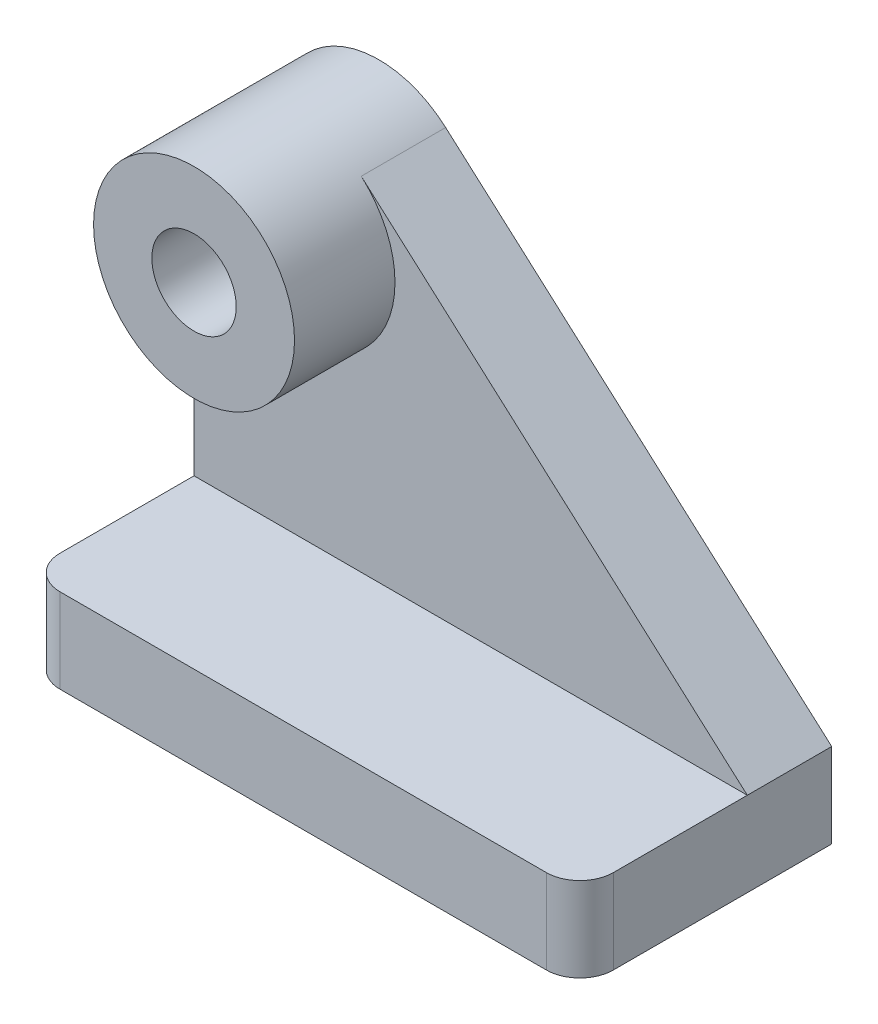
from build123d import *

# Parameters (mm, degrees)
SKETCH1_W               = 104.902
SKETCH1_H               = 47.752
EXTRUDE1_DEPTH          = 16.002
FILLET1_R               = 6.35
SKETCH2_W               = 104.902
SKETCH2_H               = 16.002
EXTRUDE2_DEPTH          = 69.85
CUT_EXTRUDE1_DEPTH      = 69.85
CUT_EXTRUDE3_DEPTH      = 32.75
CUT_EXTRUDE3_DEPTH_BACK = 17.002
SKETCH5_R               = 19.05
EXTRUDE3_DEPTH          = 19.05
SKETCH6_R               = 8.001
CUT_EXTRUDE4_DEPTH      = 36.052


with BuildPart() as part:
    # Sketch1 → Extrude1 (new body)
    with BuildSketch(Plane(origin=(0, 0, 0), x_dir=(1, 0, 0), z_dir=(0, 1, 0))):
        with Locations((-26.583821429, -19.496767857)):
            Rectangle(SKETCH1_W, SKETCH1_H)
    extrude(amount=EXTRUDE1_DEPTH)

    # Fillet1
    fillet1_edges = [part.edges().sort_by_distance(p)[0] for p in [
        (25.867178571, 8.001, 43.372767857),
        (-79.034821429, 8.001, 43.372767857),
    ]]
    fillet(fillet1_edges, radius=FILLET1_R)

    # Sketch2 → Extrude2 (add)
    with BuildSketch(Plane(origin=(0, 16.002, 0), x_dir=(-1, 0, 0), z_dir=(0, 1, 0))):
        with Locations((26.583821429, 3.621767857)):
            Rectangle(SKETCH2_W, SKETCH2_H)
    extrude(amount=EXTRUDE2_DEPTH)

    # Sketch3 → Cut-Extrude1 (cut)
    with BuildSketch(Plane.XY.offset(11.622767857)):
        with BuildLine():
            ThreePointArc((-59.984821429, 85.852), (-53.216510402, 84.609090325), (-47.331390899, 81.042547596))
            Line((-47.331390899, 81.042547596), (25.867178571, 16.002))
            Line((25.867178571, 16.002), (25.867178571, 85.852))
            Line((25.867178571, 85.852), (-59.984821429, 85.852))
        make_face()
    extrude(amount=-CUT_EXTRUDE1_DEPTH, mode=Mode.SUBTRACT)

    # Sketch4 → Cut-Extrude3 (cut, two sides)
    with BuildSketch(Plane.XY.offset(11.622767857)) as cut_extrude3_sk:
        with BuildLine():
            Line((198.747458809, 85.852), (-59.984821429, 85.852))
            ThreePointArc((-59.984821429, 85.852), (-73.45520561, 80.272384182), (-79.034821429, 66.802))
            Line((-79.034821429, 66.802), (-79.034821429, -191.930280237))
            Line((-79.034821429, -191.930280237), (-444.937521164, 173.972419498))
            Line((-444.937521164, 173.972419498), (-167.155240927, 451.754699735))
            Line((-167.155240927, 451.754699735), (198.747458809, 85.852))
        make_face()
    extrude(amount=CUT_EXTRUDE3_DEPTH, mode=Mode.SUBTRACT)
    extrude(cut_extrude3_sk.sketch, amount=-CUT_EXTRUDE3_DEPTH_BACK, mode=Mode.SUBTRACT)

    # Sketch5 → Extrude3 (add)
    with BuildSketch(Plane.XY.offset(11.622767857)):
        with Locations((-59.984821429, 66.802)):
            Circle(SKETCH5_R)
    extrude(amount=EXTRUDE3_DEPTH)

    # Sketch6 → Cut-Extrude4 (cut, through all)
    with BuildSketch(Plane.XY.offset(30.672767857)):
        with Locations((-59.984821429, 66.802)):
            Circle(SKETCH6_R)
    extrude(amount=-CUT_EXTRUDE4_DEPTH, mode=Mode.SUBTRACT)


solid = part.part
